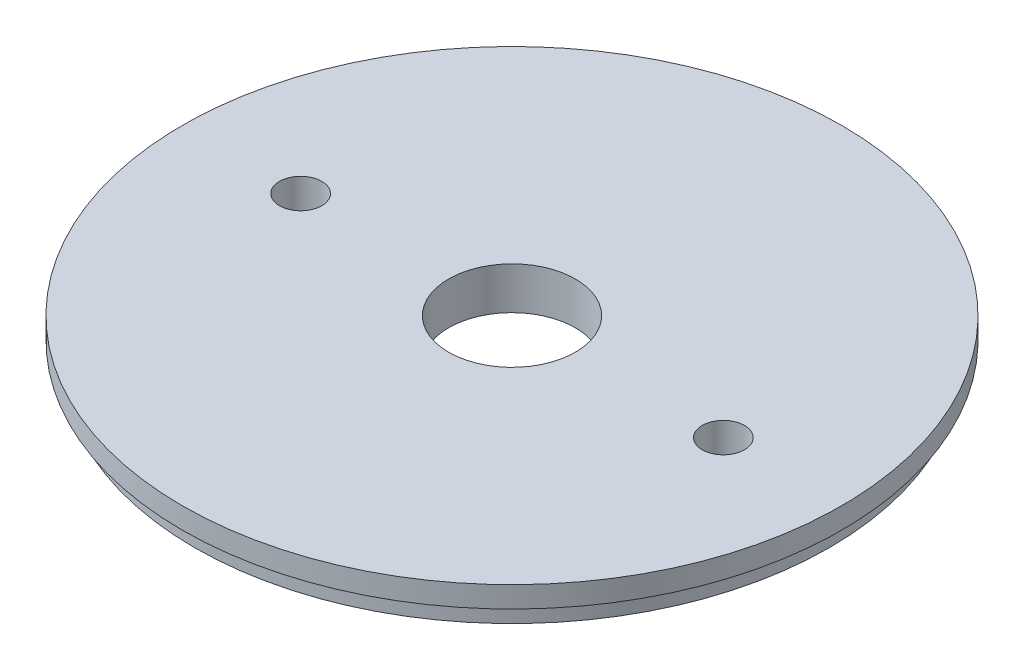
from build123d import *

# Parameters (mm, degrees)
SKETCH1_R           = 47.6885
BOSS_EXTRUDE1_DEPTH = 3.175
SKETCH2_R           = 49.5046
BOSS_EXTRUDE2_DEPTH = 3.175
SKETCH3_R           = 3.175
SKETCH3_R_2         = 9.525
CUT_EXTRUDE1_DEPTH  = 7.35


with BuildPart() as part:
    # Sketch1 → Boss-Extrude1 (new body)
    with BuildSketch(Plane(origin=(0, 0, 0), x_dir=(1, 0, 0), z_dir=(0, 1, 0))):
        Circle(SKETCH1_R)
    extrude(amount=BOSS_EXTRUDE1_DEPTH)

    # Sketch2 → Boss-Extrude2 (add)
    with BuildSketch(Plane(origin=(0, 3.175, 0), x_dir=(1, 0, 0), z_dir=(0, 1, 0))):
        Circle(SKETCH2_R)
    extrude(amount=BOSS_EXTRUDE2_DEPTH)

    # Sketch3 → Cut-Extrude1 (cut, through all)
    with BuildSketch(Plane(origin=(0, 6.35, 0), x_dir=(1, 0, 0), z_dir=(0, 1, 0))):
        with Locations((-31.75, 0)):
            Circle(SKETCH3_R)
        with Locations((31.75, 0)):
            Circle(SKETCH3_R)
        Circle(SKETCH3_R_2)
    extrude(amount=-CUT_EXTRUDE1_DEPTH, mode=Mode.SUBTRACT)


solid = part.part
